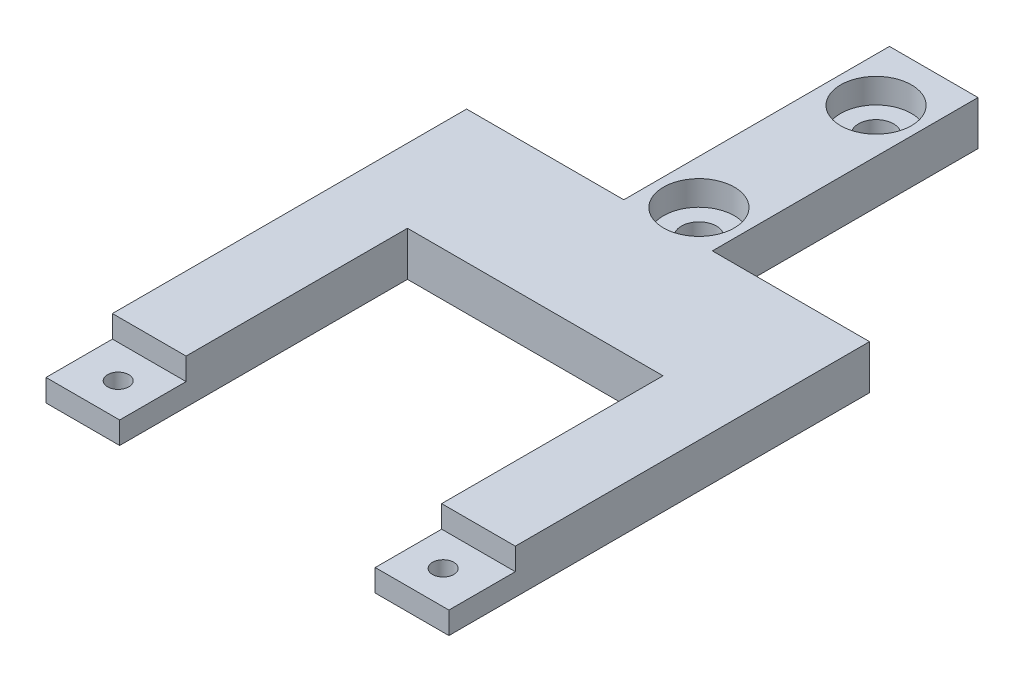
from build123d import *

# Parameters (mm, degrees)
SKETCH1_W           = 6.35
SKETCH1_H           = 19.05
BOSS_EXTRUDE1_DEPTH = 1.5875
SKETCH2_W           = 5.2832
SKETCH2_H           = 4.7625
CUT_EXTRUDE1_DEPTH  = 1.5875
SKETCH3_R           = 0.762
SKETCH3_R_2         = 1.2573
CUT_EXTRUDE2_DEPTH  = 3.175
SKETCH31_R          = 2.54
CUT_EXTRUDE5_DEPTH  = 1.778


with BuildPart() as part:
    # Sketch1 → Boss-Extrude1 (new body, symmetric)
    with BuildSketch(Plane(origin=(0, 0, 0), x_dir=(1, 0, 0), z_dir=(0, 1, 0))):
        Polygon((-3.175, 15.08125), (-14.44625, 15.08125), (-14.44625, -15.08125), (-9.16305, -15.08125), (-9.16305, 5.55625), (9.16305, 5.55625), (9.16305, -15.08125), (14.44625, -15.08125), (14.44625, 15.08125), (3.175, 15.08125), align=None)
        with Locations((0, 24.60625)):
            Rectangle(SKETCH1_W, SKETCH1_H)
    extrude(amount=BOSS_EXTRUDE1_DEPTH, both=True)

    # Sketch2 → Cut-Extrude1 (cut)
    with BuildSketch(Plane(origin=(0, 1.5875, 0), x_dir=(1, 0, 0), z_dir=(0, 1, 0))):
        with Locations((-11.80465, -12.7)):
            Rectangle(SKETCH2_W, SKETCH2_H)
        with Locations((11.80465, -12.7)):
            Rectangle(SKETCH2_W, SKETCH2_H)
    extrude(amount=-CUT_EXTRUDE1_DEPTH, mode=Mode.SUBTRACT)

    # Sketch3 → Cut-Extrude2 (cut)
    with BuildSketch(Plane(origin=(0, 1.5875, 0), x_dir=(1, 0, 0), z_dir=(0, 1, 0))):
        with Locations((-11.65225, -12.7)):
            Circle(SKETCH3_R)
        with Locations((11.65225, -12.7)):
            Circle(SKETCH3_R)
        with Locations((0, 17.294029814)):
            Circle(SKETCH3_R_2)
        with Locations((0, 29.994029814)):
            Circle(SKETCH3_R_2)
    extrude(amount=-CUT_EXTRUDE2_DEPTH, mode=Mode.SUBTRACT)

    # Sketch31 → Cut-Extrude5 (cut)
    with BuildSketch(Plane(origin=(0, 1.5875, 0), x_dir=(1, 0, 0), z_dir=(0, 1, 0))):
        with Locations((0, 17.294029814)):
            Circle(SKETCH31_R)
        with Locations((0, 29.994029814)):
            Circle(SKETCH31_R)
    extrude(amount=-CUT_EXTRUDE5_DEPTH, mode=Mode.SUBTRACT)


solid = part.part
